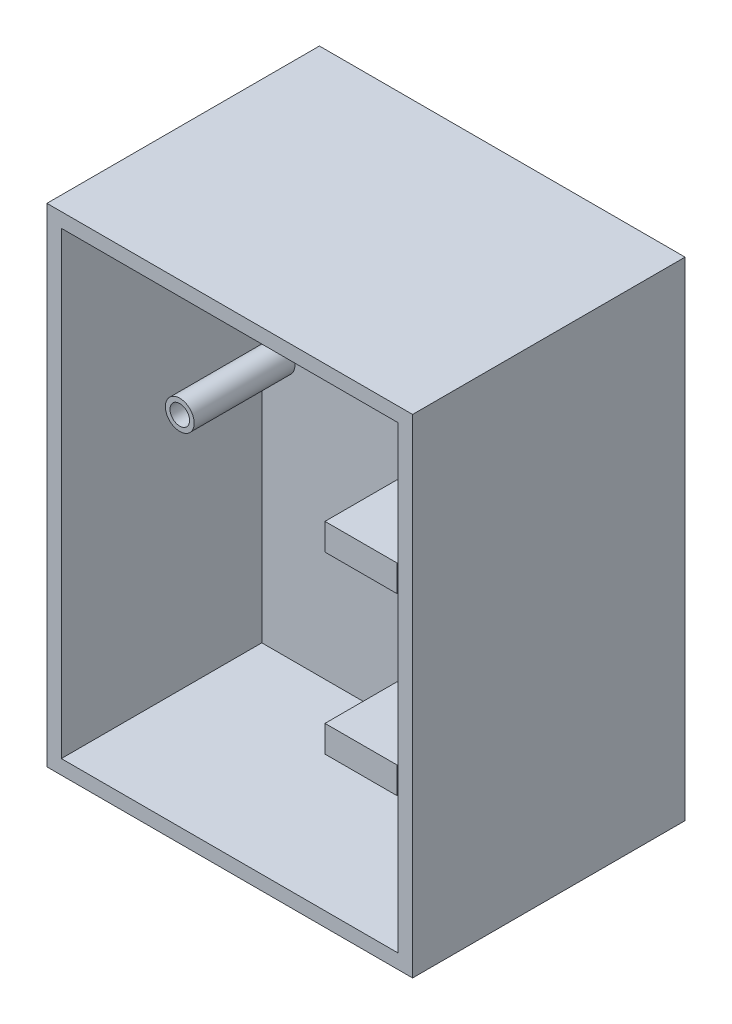
from build123d import *

# Parameters (mm, degrees)
SKETCH1_W                 = 64.4906
SKETCH1_H                 = 86.0806
SKETCH1_W_2               = 59.4106
SKETCH1_H_2               = 81.0006
EXTRUDE_THIN1_DEPTH       = 35.3568
SKETCH2_W                 = 64.4906
SKETCH2_H                 = 86.0806
BOSS_EXTRUDE1_DEPTH       = 12.7
SKETCH3_W                 = 12.7
SKETCH3_H                 = 4.692408937
BOSS_EXTRUDE3_DEPTH       = 12.7
BOSS_EXTRUDE4_DEPTH       = 17.78
F_8_32_TAPPED_HOLE1_D     = 3.4544
F_8_32_TAPPED_HOLE1_DEPTH = 18.796
F_8_32_TAPPED_HOLE1_TIP   = 1.037806461


with BuildPart() as part:
    # Sketch1 → Extrude-Thin1 (new body)
    with BuildSketch(Plane.XY):
        Rectangle(SKETCH1_W, SKETCH1_H)
        Rectangle(SKETCH1_W_2, SKETCH1_H_2, mode=Mode.SUBTRACT)
    extrude(amount=EXTRUDE_THIN1_DEPTH)

    # Sketch2 → Boss-Extrude1 (add)
    with BuildSketch(Plane(origin=(0, 0, 0), x_dir=(-1, 0, 0), z_dir=(0, 0, -1))):
        Rectangle(SKETCH2_W, SKETCH2_H)
    extrude(amount=BOSS_EXTRUDE1_DEPTH)

    # Sketch3 → Boss-Extrude3 (add)
    with BuildSketch(Plane.XY):
        with Locations((0.486291995, -6.023095532)):
            Rectangle(SKETCH3_W, SKETCH3_H)
        with Locations((0.486291995, -36.877504469)):
            Rectangle(SKETCH3_W, SKETCH3_H)
    extrude(amount=BOSS_EXTRUDE3_DEPTH)

    # Sketch5 → Boss-Extrude4 (add)
    with BuildSketch(Plane.XY):
        with BuildLine():
            Line((-26.393952246, 7.409416617), (-26.393952246, 4.869416617))
            Line((-26.393952246, 4.869416617), (-23.853952246, 4.869416617))
            ThreePointArc((-23.853952246, 4.869416617), (-24.597901022, 6.665467841), (-26.393952246, 7.409416617))
        make_face()
        with BuildLine():
            Line((-23.853952246, 4.869416617), (-26.393952246, 4.869416617))
            Line((-26.393952246, 4.869416617), (-26.393952246, 7.409416617))
            ThreePointArc((-26.393952246, 7.409416617), (-28.19000347, 3.073365392), (-23.853952246, 4.869416617))
        make_face()
        with BuildLine():
            ThreePointArc((-23.853952246, 35.630883383), (-28.19000347, 37.426934608), (-26.393952246, 33.090883383))
            Line((-26.393952246, 33.090883383), (-26.393952246, 35.630883383))
            Line((-26.393952246, 35.630883383), (-23.853952246, 35.630883383))
        make_face()
        with BuildLine():
            Line((-26.393952246, 35.630883383), (-26.393952246, 33.090883383))
            ThreePointArc((-26.393952246, 33.090883383), (-24.597901022, 33.834832159), (-23.853952246, 35.630883383))
            Line((-23.853952246, 35.630883383), (-26.393952246, 35.630883383))
        make_face()
        with BuildLine():
            ThreePointArc((26.393952246, 22.79015), (23.853952246, 20.25015), (26.393952246, 17.71015))
            Line((26.393952246, 17.71015), (26.393952246, 22.79015))
        make_face()
        with BuildLine():
            Line((26.393952246, 22.79015), (26.393952246, 17.71015))
            ThreePointArc((26.393952246, 17.71015), (28.19000347, 18.454098776), (28.933952246, 20.25015))
            ThreePointArc((28.933952246, 20.25015), (28.19000347, 22.046201224), (26.393952246, 22.79015))
        make_face()
        with BuildLine():
            ThreePointArc((26.393952246, 8.878390919), (24.137539747, 7.504668174), (24.321824233, 4.869416617))
            Line((24.321824233, 4.869416617), (26.393952246, 4.869416617))
            Line((26.393952246, 4.869416617), (26.393952246, 8.878390919))
        make_face()
        with BuildLine():
            Line((26.393952246, 4.869416617), (24.321824233, 4.869416617))
            ThreePointArc((24.321824233, 4.869416617), (27.164794269, 3.918183784), (28.933952246, 6.338390919))
            ThreePointArc((28.933952246, 6.338390919), (28.19000347, 8.134442143), (26.393952246, 8.878390919))
            Line((26.393952246, 8.878390919), (26.393952246, 4.869416617))
        make_face()
    extrude(amount=BOSS_EXTRUDE4_DEPTH)

    # #8-32 Tapped Hole1
    with Locations(Plane(origin=(-26.393952246, 4.869416617, 17.78), x_dir=(1, 0, 0), z_dir=(0, 0, 1))):
        with Locations((0, 0), (0, 30.761466766), (52.787904492, 15.380733383), (52.787904492, 1.468974302)):
            Hole(F_8_32_TAPPED_HOLE1_D / 2, depth=F_8_32_TAPPED_HOLE1_DEPTH)
            with Locations((0, 0, -(F_8_32_TAPPED_HOLE1_DEPTH + F_8_32_TAPPED_HOLE1_TIP / 2))):  # 118° drill point
                Cone(0, F_8_32_TAPPED_HOLE1_D / 2, F_8_32_TAPPED_HOLE1_TIP, mode=Mode.SUBTRACT)


solid = part.part
